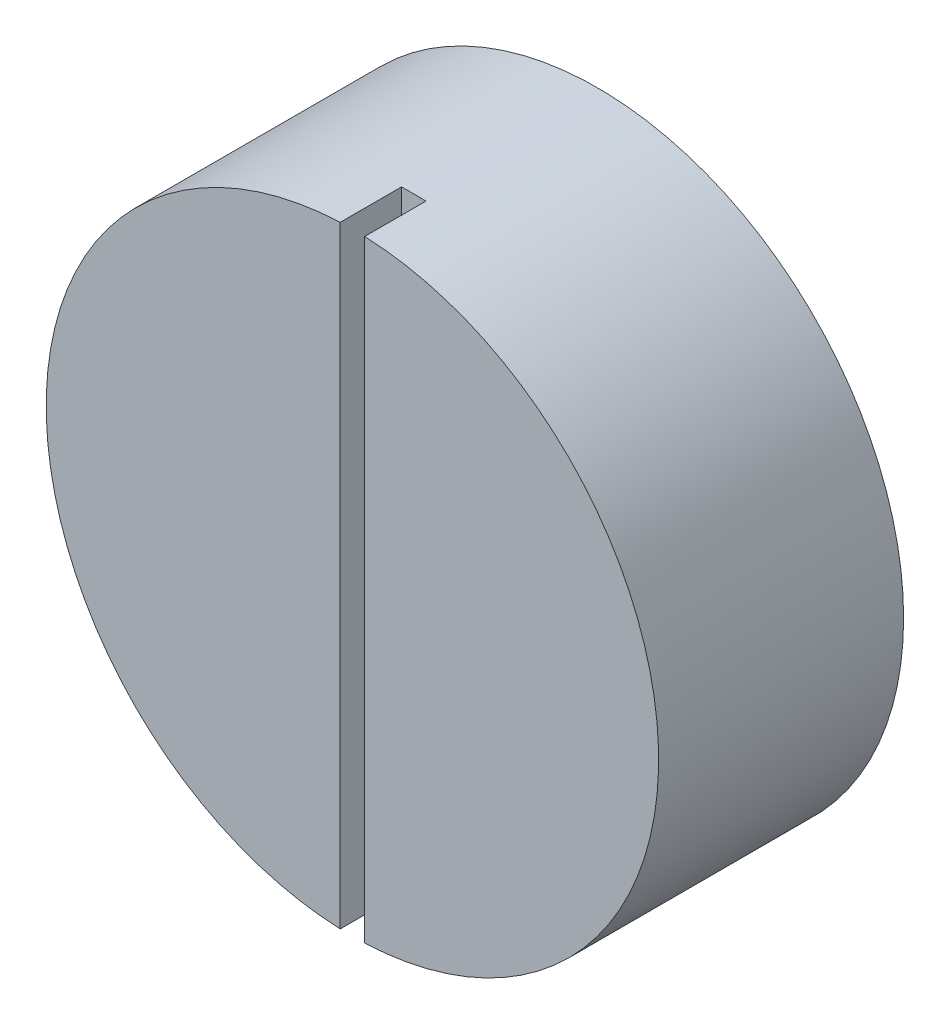
from build123d import *

# Parameters (mm, degrees)
SKETCH1_R           = 25
BOSS_EXTRUDE1_DEPTH = 20
SKETCH2_W           = 2
SKETCH2_H           = 50
CUT_EXTRUDE1_DEPTH  = 5


with BuildPart() as part:
    # Sketch1 → Boss-Extrude1 (new body)
    with BuildSketch(Plane.XY):
        Circle(SKETCH1_R)
    extrude(amount=BOSS_EXTRUDE1_DEPTH)

    # Sketch2 → Cut-Extrude1 (cut)
    with BuildSketch(Plane.XY.offset(20)):
        Rectangle(SKETCH2_W, SKETCH2_H)
    extrude(amount=-CUT_EXTRUDE1_DEPTH, mode=Mode.SUBTRACT)


solid = part.part
